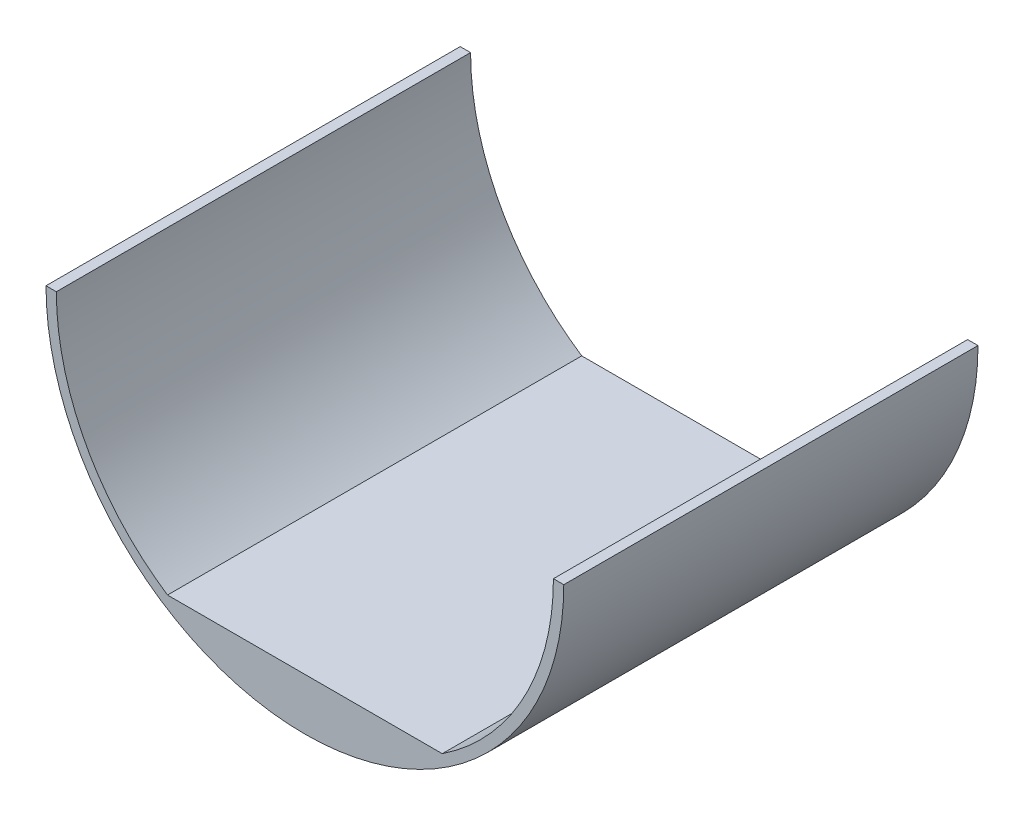
from build123d import *

# Parameters (mm, degrees)
BOSS_EXTRUDE3_DEPTH = 101.6


with BuildPart() as part:
    # Sketch3 → Boss-Extrude3 (new body)
    with BuildSketch(Plane.XY):
        with BuildLine():
            Line((63.5, 0), (60.96, 0))
            ThreePointArc((60.96, 0), (53.713522989, -28.826707202), (33.69690787, -50.8))
            ThreePointArc((33.69690787, -50.8), (0, -60.96), (-33.69690787, -50.8))
            ThreePointArc((-33.69690787, -50.8), (-53.713522989, -28.826707202), (-60.96, 0))
            Line((-60.96, 0), (-63.5, 0))
            ThreePointArc((-63.5, 0), (0, -63.5), (63.5, 0))
        make_face()
        with BuildLine():
            ThreePointArc((-33.69690787, -50.8), (0, -60.96), (33.69690787, -50.8))
            Line((33.69690787, -50.8), (-33.69690787, -50.8))
        make_face()
    extrude(amount=BOSS_EXTRUDE3_DEPTH)


solid = part.part
